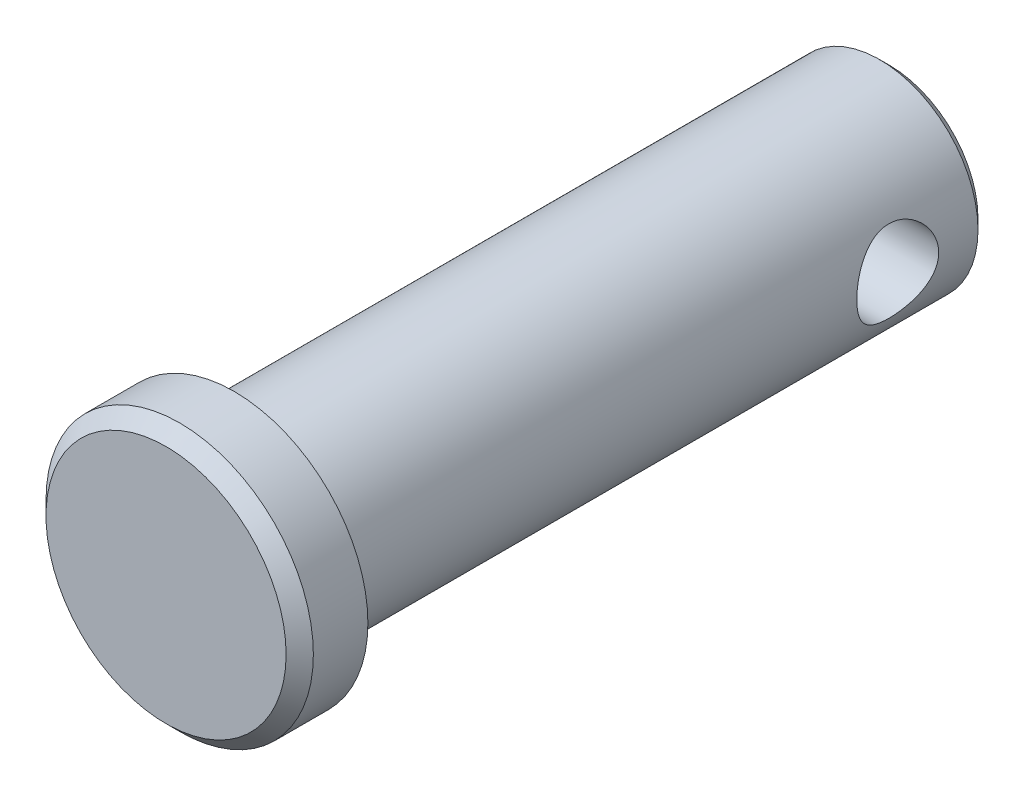
from build123d import *

# Parameters (mm, degrees)
SKETCH1_R           = 4.7625
EXTRUDE1_DEPTH      = 15.875
SKETCH2_R           = 6.477
EXTRUDE2_DEPTH      = 3.302
CHAMFER1_SIZE       = 0.6604
SKETCH3_R           = 1.984375
EXTRUDE3_DEPTH      = 7.477
EXTRUDE3_DEPTH_BACK = 7.477
CHAMFER2_SIZE       = 0.47625


with BuildPart() as part:
    # Sketch1 → Extrude1 (new body, symmetric)
    with BuildSketch(Plane.XY):
        Circle(SKETCH1_R)
    extrude(amount=EXTRUDE1_DEPTH, both=True)

    # Sketch2 → Extrude2 (add)
    with BuildSketch(Plane.XY.offset(15.875)):
        Circle(SKETCH2_R)
    extrude(amount=EXTRUDE2_DEPTH)

    # Chamfer1
    chamfer1_edges = [part.edges().sort_by_distance(p)[0] for p in [
        (-6.477, 0, 19.177),
    ]]
    chamfer(chamfer1_edges, length=CHAMFER1_SIZE)

    # Sketch3 → Extrude3 (cut, two sides)
    with BuildSketch(Plane(origin=(0, 0, 0), x_dir=(0, 0, -1), z_dir=(1, 0, 0))) as extrude3_sk:
        with Locations((11.509375, 0)):
            Circle(SKETCH3_R)
    extrude(amount=EXTRUDE3_DEPTH, mode=Mode.SUBTRACT)
    extrude(extrude3_sk.sketch, amount=-EXTRUDE3_DEPTH_BACK, mode=Mode.SUBTRACT)

    # Chamfer2
    chamfer2_edges = [part.edges().sort_by_distance(p)[0] for p in [
        (-4.7625, 0, -15.875),
    ]]
    chamfer(chamfer2_edges, length=CHAMFER2_SIZE)


solid = part.part
